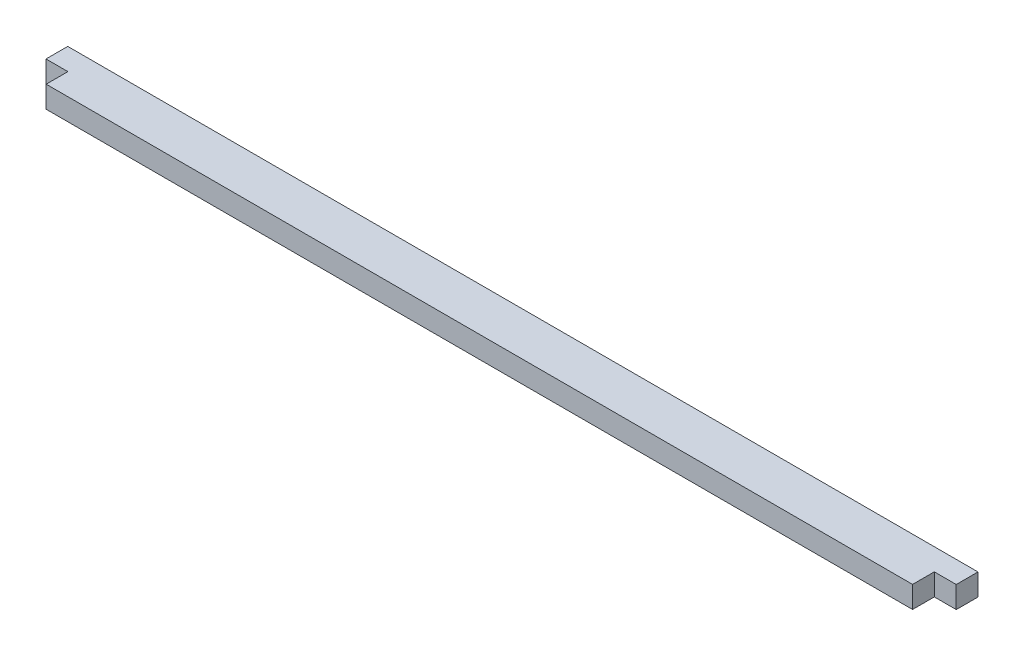
from build123d import *

# Parameters (mm, degrees)
BOSS_EXTRUDE1_DEPTH = 3.175


with BuildPart() as part:
    # Sketch2 → Boss-Extrude1 (new body)
    with BuildSketch(Plane(origin=(0, 0, 0), x_dir=(1, 0, 0), z_dir=(0, 1, 0))):
        Polygon((3.2004, -6.35), (129.6543, -6.35), (129.6543, -3.175), (132.8547, -3.175), (132.8547, 0), (0, 0), (0, -3.175), (3.2004, -3.175), align=None)
    extrude(amount=BOSS_EXTRUDE1_DEPTH)


solid = part.part
